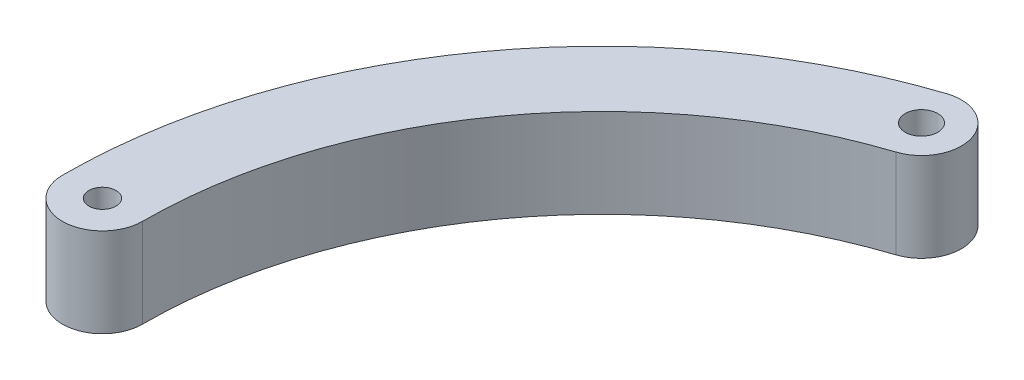
from build123d import *

# Parameters (mm, degrees)
SKETCH1_R           = 0.9921875
SKETCH1_R_2         = 1.190625
BOSS_EXTRUDE1_DEPTH = 6.51002


with BuildPart() as part:
    # Sketch1 → Boss-Extrude1 (new body)
    with BuildSketch(Plane(origin=(0, 0, 0), x_dir=(1, 0, 0), z_dir=(0, 1, 0))):
        with BuildLine():
            ThreePointArc((-33.590510807, 0), (-27.195497439, 19.716169387), (-10.445442396, 31.925149168))
            ThreePointArc((-10.445442396, 31.925149168), (-8.576954256, 35.610904689), (-12.262709777, 37.479392829))
            ThreePointArc((-12.262709777, 37.479392829), (-31.926890188, 23.146330613), (-39.434489193, 0))
            ThreePointArc((-39.434489193, 0), (-36.5125, -2.921989193), (-33.590510807, 0))
        make_face()
        with Locations((-36.5125, 0)):
            Circle(SKETCH1_R, mode=Mode.SUBTRACT)
        with Locations((-11.354076087, 34.702270999)):
            Circle(SKETCH1_R_2, mode=Mode.SUBTRACT)
    extrude(amount=BOSS_EXTRUDE1_DEPTH)


solid = part.part
